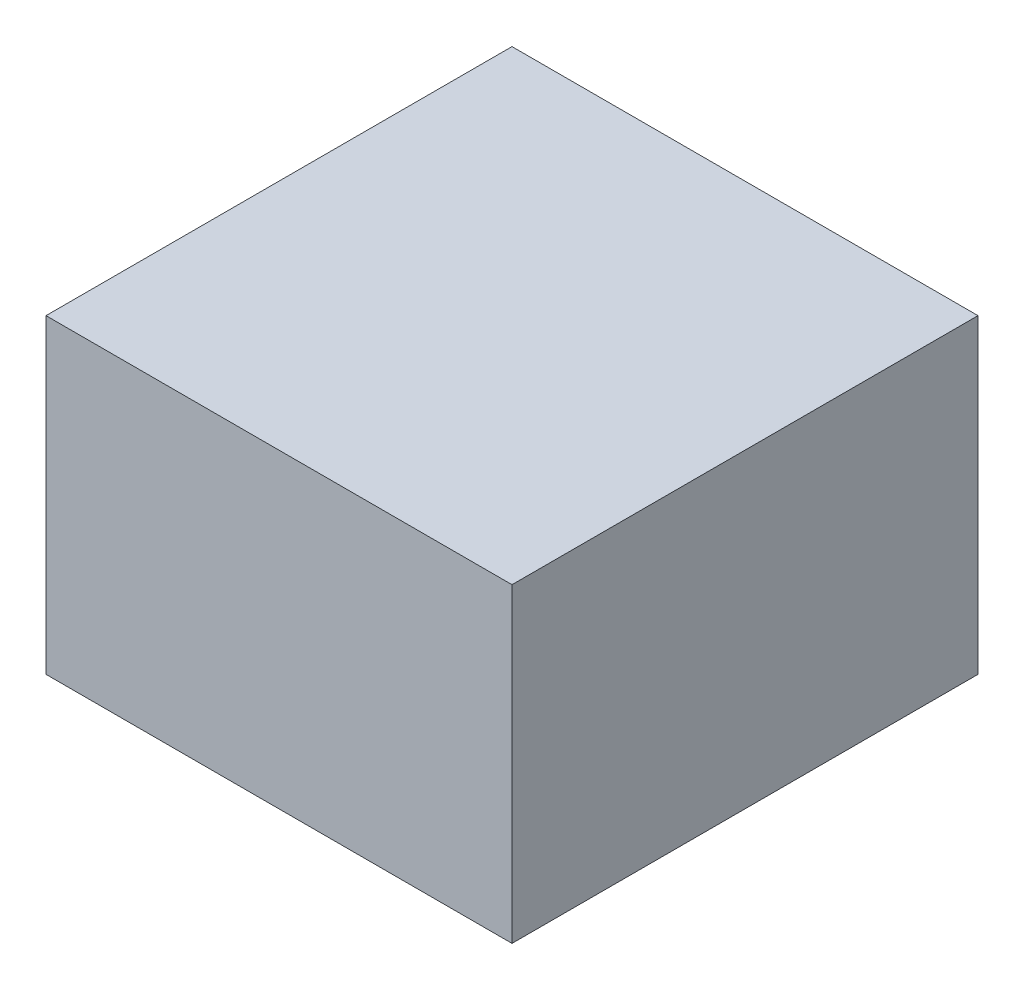
from build123d import *

# Parameters (mm, degrees)
SKETCH1_W           = 76.2
SKETCH1_H           = 76.2
BOSS_EXTRUDE1_DEPTH = 50.8


with BuildPart() as part:
    # Sketch1 → Boss-Extrude1 (new body)
    with BuildSketch(Plane(origin=(0, 0, 0), x_dir=(1, 0, 0), z_dir=(0, 1, 0))):
        with Locations((38.1, -38.1)):
            Rectangle(SKETCH1_W, SKETCH1_H)
    extrude(amount=BOSS_EXTRUDE1_DEPTH)


solid = part.part
